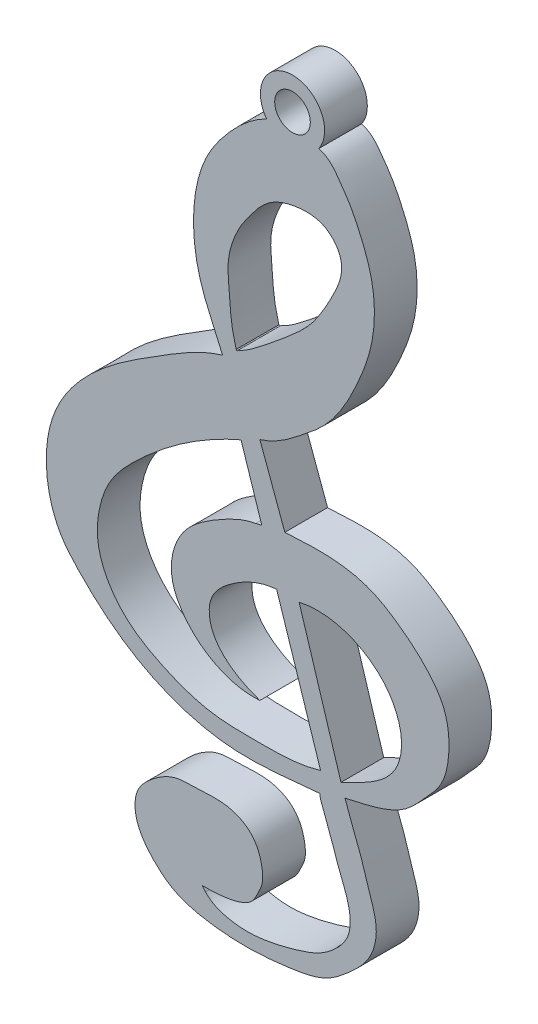
from build123d import *

# Parameters (mm, degrees)
CROQUIS1_R              = 1
SALIENTE_EXTRUIR1_DEPTH = 2.4


with BuildPart() as part:
    # Croquis1 → Saliente-Extruir1 (new body)
    with BuildSketch(Plane.XY):
        with BuildLine():
            add(Edge.make_bspline(
                [(-73.382843904, 21.485172649), (-72.816279322, 21.352562277), (-72.290048161, 20.617939926), (-71.563359458, 19.572554368), (-70.955369846, 18.303271377), (-70.180325761, 16.279733813), (-70.210087208, 13.6244299), (-71.118438702, 11.274052597), (-72.034700283, 9.43128208), (-73.060953827, 8.093199889), (-74.176463418, 7.211487575), (-75.245307097, 6.341435028), (-76.105343924, 5.854934057), (-76.688929455, 5.678784709)],
                knots=[0, 0, 0, 0, 0.082720072, 0.13560082, 0.197595917, 0.299487219, 0.46892434, 0.591754444, 0.687028642, 0.786865301, 0.848882337, 0.906336095, 1, 1, 1, 1], degree=3))
            Line((-76.688929455, 5.678784709), (-75.288653219, 1.867168619))
            add(Edge.make_bspline(
                [(-75.288653219, 1.867168619), (-74.468411952, 1.908252334), (-72.872577878, 2.015461097), (-70.631463745, 1.675125729), (-68.810384606, 0.565616098), (-67.389820174, -0.62554349), (-66.153734293, -2.256742458), (-65.96167945, -4.235010195), (-66.365441771, -6.009358939), (-67.459170254, -7.148174835), (-68.270466433, -8.123187694), (-69.854703917, -8.959771389), (-71.054207735, -9.166320913), (-71.906140878, -9.374564164)],
                knots=[0, 0, 0, 0, 0.11762295, 0.230289999, 0.317392698, 0.419586807, 0.496456837, 0.603597023, 0.693697186, 0.746523704, 0.827441455, 0.873617317, 1, 1, 1, 1], degree=3))
            add(Edge.make_bspline(
                [(-71.906140878, -9.374564164), (-71.61278094, -10.266839308), (-71.036756395, -11.553098269), (-70.528271485, -13.35950605), (-70.000664218, -14.794214547), (-70.38948534, -16.535052776), (-71.615071455, -17.699585086), (-73.060823598, -18.884419966), (-74.955161604, -19.19978755), (-77.241867683, -19.438869557), (-79.443104395, -19.317828204), (-81.433845047, -18.830999441), (-82.464748145, -17.980329563), (-83.140965101, -17.252480478), (-83.593955092, -16.480808011), (-83.752954974, -15.617546025), (-83.608641776, -14.78603997), (-83.194756323, -14.263514026), (-82.702884853, -13.823597136), (-82.179262793, -13.441681166), (-81.432137939, -13.092921965), (-80.517138878, -13.064254835), (-79.492506239, -13.016435402), (-78.279139352, -13.020538301), (-77.016213715, -13.666355282), (-76.555165276, -14.862084339), (-76.488557331, -15.83888893), (-76.815315899, -16.458860603), (-77.065125243, -17.020204619), (-77.742898732, -17.401740743), (-78.706718276, -17.603569236), (-79.482690885, -17.645040657), (-79.925056233, -17.629067046)],
                knots=[0, 0, 0, 0, 0.074805241, 0.11132212, 0.149630483, 0.194577694, 0.242981274, 0.281554535, 0.341328008, 0.390461965, 0.465398944, 0.516027146, 0.549472808, 0.569857733, 0.595053118, 0.619442754, 0.638197686, 0.660324416, 0.670723298, 0.690791225, 0.711746454, 0.73503389, 0.762613743, 0.793710312, 0.830998489, 0.86650762, 0.890979006, 0.905817433, 0.921675854, 0.938569682, 0.964778851, 1, 1, 1, 1], degree=3))
            add(Edge.make_bspline(
                [(-79.745792871, -17.851802825), (-79.925056233, -17.629067046)],
                knots=[0, 0, 1, 1], degree=1))
            add(Edge.make_bspline(
                [(-79.745792871, -17.851802825), (-79.377728082, -18.250457197), (-78.598905688, -18.510175961), (-77.445529422, -18.641537901), (-76.334832164, -18.54753779), (-75.193190702, -18.291470417), (-74.157420098, -17.982791531), (-73.328642935, -17.655936573), (-72.674800508, -17.19664297), (-72.136943705, -16.684677178), (-71.725059461, -16.078199587), (-71.557910168, -15.250749341), (-71.729283252, -14.277038523), (-72.075975491, -13.411558538), (-72.37751376, -12.660176729), (-72.546628338, -12.092589849), (-72.748229841, -11.588348302), (-72.895787934, -11.112644121), (-73.065295019, -10.700797712), (-73.235237824, -10.283342723), (-73.317254276, -10.026629889), (-73.326078886, -9.853276729)],
                knots=[0, 0, 0, 0, 0.100297216, 0.155435072, 0.224439636, 0.315020887, 0.381826218, 0.433978194, 0.486800826, 0.535484251, 0.577523687, 0.626710452, 0.694737543, 0.765895596, 0.807411146, 0.851576548, 0.88054523, 0.912596844, 0.948032108, 0.966788769, 1, 1, 1, 1], degree=3))
            add(Edge.make_bspline(
                [(-73.326078886, -9.853276729), (-74.979679959, -9.995751786), (-78.452282633, -10.49535985), (-83.388178533, -8.914488142), (-86.275432814, -6.495055205), (-87.957194856, -4.564365563), (-88.570288982, -2.996611158), (-88.775793899, -1.013821722), (-88.306004497, 1.729575325), (-85.949537881, 4.676575), (-82.425763739, 6.869714587), (-80.045029758, 8.359671299), (-78.783962186, 8.735087678)],
                knots=[0, 0, 0, 0, 0.144810891, 0.29982304, 0.43227727, 0.467632746, 0.520861501, 0.574899367, 0.63945409, 0.757272263, 0.88708928, 1, 1, 1, 1], degree=3))
            add(Edge.make_bspline(
                [(-78.783962186, 8.735087678), (-79.148845445, 9.634457766), (-80.225036896, 11.646609291), (-80.612874405, 14.950152713), (-79.907852199, 17.82628115), (-78.379717416, 19.921328754), (-77.201516961, 21.020487171), (-76.3154098, 21.464690957)],
                knots=[0, 0, 0, 0, 0.201335738, 0.468683326, 0.668300446, 0.798365415, 1, 1, 1, 1], degree=3))
            ThreePointArc((-76.3154098, 21.464690957), (-74.869048258, 24.327275938), (-73.382843904, 21.485172649))
        make_face()
        with Locations((-74.856455338, 22.524223385)):
            Circle(CROQUIS1_R, mode=Mode.SUBTRACT)
        with BuildLine():
            Line((-74.484460646, -1.133595475), (-72.133027249, -8.716968179))
            add(Edge.make_bspline(
                [(-74.484460646, -1.133595475), (-73.283378869, -0.850339229), (-71.440115738, -1.186045151), (-69.63352513, -2.610213082), (-68.835374903, -3.973046003), (-68.644563627, -5.376781633), (-69.097791243, -6.878034458), (-70.443842904, -7.955321849), (-71.594543517, -8.436745129), (-72.133027249, -8.716968179)],
                knots=[0, 0, 0, 0, 0.278394154, 0.399126556, 0.515243262, 0.629976033, 0.711946034, 0.862107141, 1, 1, 1, 1], degree=3))
        make_face(mode=Mode.SUBTRACT)
        with BuildLine():
            add(Edge.make_bspline(
                [(-77.928016672, 9.39589872), (-77.977009898, 9.316591026), (-78.022202288, 9.39589872)],
                knots=[0, 0, 0, 1, 1, 1], degree=2))
            add(Edge.make_bspline(
                [(-78.022202288, 9.39589872), (-78.112248491, 9.743130089), (-78.284610236, 10.407782258), (-78.36421323, 11.409395561), (-78.43433762, 12.340152669), (-78.512865884, 13.222993811), (-78.400129242, 13.997240727), (-78.145886099, 14.774699767), (-77.782315961, 15.558796545), (-77.239268592, 16.313589804), (-76.698081348, 17.018136895), (-75.948448577, 17.679765585), (-74.922434231, 18.019394979), (-73.923097777, 18.108525469), (-72.826532687, 17.872003144), (-72.062827891, 16.965972459), (-72.102821748, 15.783989767), (-72.52046451, 14.856380567), (-73.10790887, 13.752968837), (-73.778471189, 12.706556273), (-74.678093213, 11.851215915), (-75.618461258, 11.048901475), (-76.628439152, 10.234767882), (-77.424220679, 9.64031082), (-77.86765592, 9.425182197), (-77.928016672, 9.39589872)],
                knots=[0, 0, 0, 0, 0.046234465, 0.088499601, 0.129376126, 0.166981464, 0.202560649, 0.229435641, 0.272508236, 0.313509199, 0.349201554, 0.387286028, 0.440602524, 0.485479344, 0.515571404, 0.583511224, 0.614581517, 0.664465849, 0.712996668, 0.776704411, 0.823500625, 0.87268466, 0.936376551, 0.991339526, 1, 1, 1, 1], degree=3))
        make_face(mode=Mode.SUBTRACT)
        with BuildLine():
            Line((-75.748356097, -1.133595475), (-73.27935103, -8.716968179))
            add(Edge.make_bspline(
                [(-73.27935103, -8.716968179), (-74.54403941, -9.099328125), (-76.597852728, -9.085833404), (-79.644615755, -9.068104931), (-81.932302943, -8.226273805), (-83.957404242, -7.110551081), (-85.273526187, -5.621380732), (-85.914909067, -3.853044747), (-85.759925302, -2.201384209), (-85.282619327, -0.736042917), (-84.392643233, 0.456217849), (-83.27080941, 1.539666913), (-81.207549469, 3.314419204), (-79.282403907, 4.472508042), (-77.747782265, 5.134297209)],
                knots=[0, 0, 0, 0, 0.140602397, 0.223478455, 0.328347819, 0.401004637, 0.472812394, 0.539192635, 0.598886041, 0.649529088, 0.70484218, 0.758150444, 0.818924333, 1, 1, 1, 1], degree=3))
            Line((-77.747782265, 5.134297209), (-76.583774396, 1.559130182))
            add(Edge.make_bspline(
                [(-76.583774396, 1.559130182), (-76.924072795, 1.482374179)],
                knots=[0, 0, 1, 1], degree=1))
            add(Edge.make_bspline(
                [(-76.688929455, -7.012178967), (-77.779962606, -7.101137668), (-79.354199759, -6.611511351), (-80.90825158, -5.19158372), (-81.724995865, -3.79418853), (-81.664670946, -2.150791159), (-80.978762427, -0.807113786), (-80.041282643, -0.014701178), (-79.235120023, 0.503541817), (-78.26137141, 1.051323643), (-77.500345123, 1.381049705), (-76.924072795, 1.482374179)],
                knots=[0, 0, 0, 0, 0.22965919, 0.335098219, 0.44680271, 0.56432709, 0.670369882, 0.760787276, 0.823624202, 0.875763436, 1, 1, 1, 1], degree=3))
            add(Edge.make_bspline(
                [(-76.688929455, -7.012178967), (-77.740334836, -6.669763356), (-79.493284206, -5.687330151), (-79.609713646, -3.253547132), (-78.048029923, -1.823215334), (-76.690901104, -1.21666721), (-75.748356097, -1.133595475)],
                knots=[0, 0, 0, 0, 0.383378054, 0.51727079, 0.709392586, 1, 1, 1, 1], degree=3))
        make_face(mode=Mode.SUBTRACT)
    extrude(amount=SALIENTE_EXTRUIR1_DEPTH)


solid = part.part
